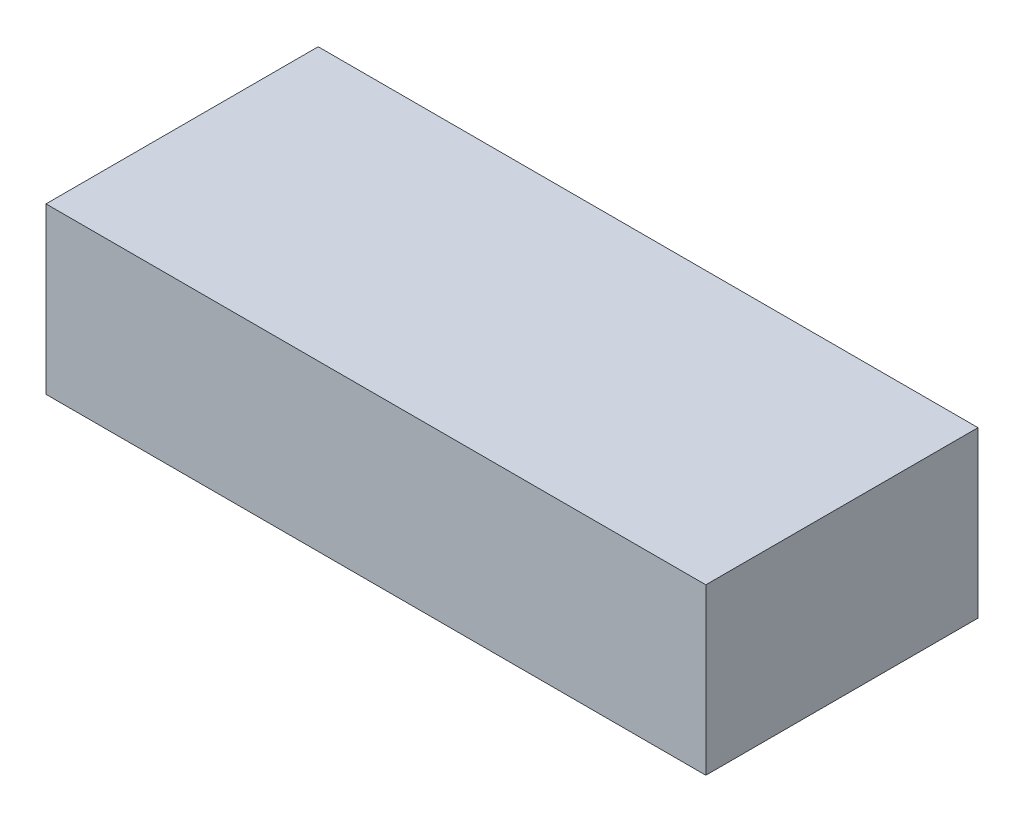
from build123d import *

# Parameters (mm, degrees)
SKETCH1_W           = 80
SKETCH1_H           = 33
BOSS_EXTRUDE1_DEPTH = 20


with BuildPart() as part:
    # Sketch1 → Boss-Extrude1 (new body)
    with BuildSketch(Plane(origin=(0, 0, 0), x_dir=(1, 0, 0), z_dir=(0, 1, 0))):
        with Locations((-7.142857143, 0)):
            Rectangle(SKETCH1_W, SKETCH1_H)
    extrude(amount=BOSS_EXTRUDE1_DEPTH)


solid = part.part
